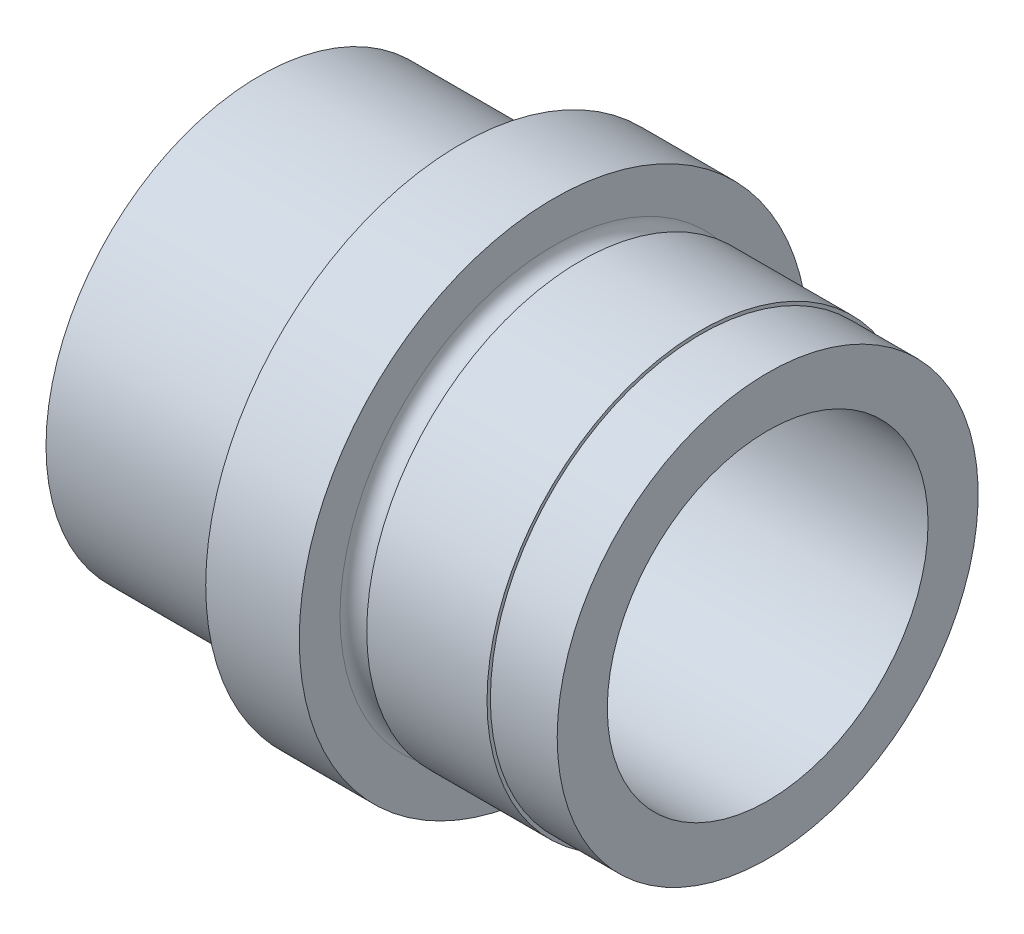
from build123d import *


with BuildPart() as part:
    # Esboço1 → Revolução1 (revolve)
    with BuildSketch(Plane.XY, mode=Mode.PRIVATE) as revolu_o1_sk:
        with BuildLine():
            Line((0, 12.25), (0, 16))
            Line((0, 16), (13, 16))
            ThreePointArc((13, 16), (14, 15), (15, 16))
            Line((15, 16), (15, 19.05))
            Line((15, 19.05), (22, 19.05))
            Line((22, 19.05), (22, 16))
            ThreePointArc((22, 16), (23, 15), (24, 16))
            Line((24, 16), (33, 16))
            Line((33, 16), (33, 15.75))
            Line((33, 15.75), (38, 15.75))
            Line((38, 15.75), (38, 12))
            Line((38, 12), (5, 12))
            Line((5, 12), (5, 12.25))
            Line((5, 12.25), (0, 12.25))
        make_face()
    revolve(revolu_o1_sk.sketch.rotate(Axis((-90.616216216, 0, 0), (1, 0, 0)), 90), axis=Axis((-90.616216216, 0, 0), (1, 0, 0)))  # turned: the seam where the file's is


solid = part.part
